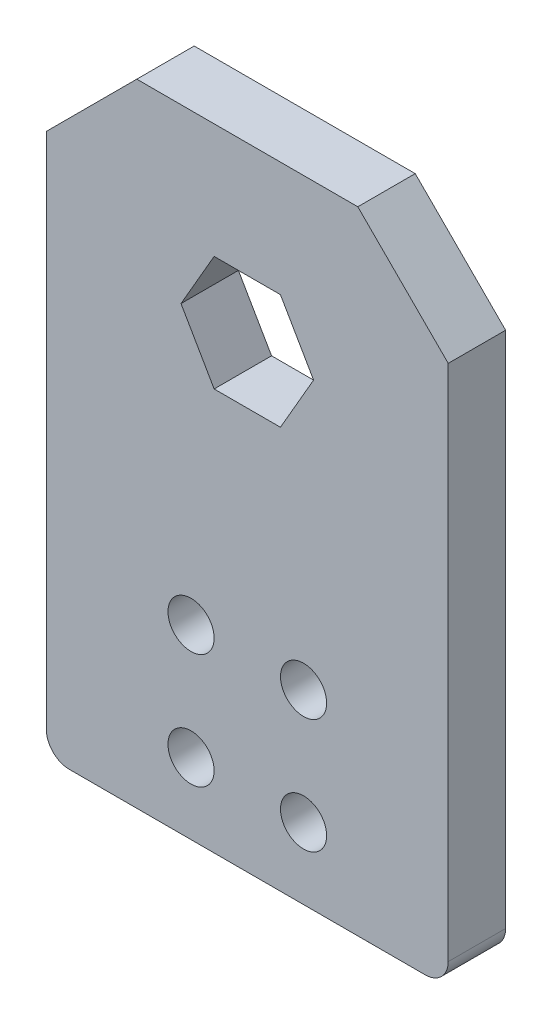
from build123d import *

# Parameters (mm, degrees)
SKETCH1_W                      = 44.45
SKETCH1_H                      = 69.85
BOSS_EXTRUDE1_DEPTH            = 3.175
CHAMFER1_SIZE                  = 10
CUT_EXTRUDE1_DEPTH             = 42.881126418
TAP_DRILL_FOR_10_24_TAP1_D     = 3.7973
TAP_DRILL_FOR_10_24_TAP1_DEPTH = 19.05
TAP_DRILL_FOR_10_24_TAP1_TIP   = 1.140824014
F_10_CLEARANCE_HOLE1_D         = 5.1054
F_10_CLEARANCE_HOLE1_DEPTH     = 12.7
F_10_CLEARANCE_HOLE1_TIP       = 1.533816902
FILLET1_R                      = 2.54


with BuildPart() as part:
    # Sketch1 → Boss-Extrude1 (new, symmetric)
    with BuildSketch(Plane.XY):
        Rectangle(SKETCH1_W, SKETCH1_H)
    extrude(amount=BOSS_EXTRUDE1_DEPTH, both=True)

    # Chamfer1
    chamfer1_edges = [part.edges().sort_by_distance(p)[0] for p in [
        (22.225, 34.925, 0),
        (-22.225, 34.925, 0),
    ]]
    chamfer(chamfer1_edges, length=CHAMFER1_SIZE)

    # Sketch2 → Cut-Extrude1 (cut, through all)
    with BuildSketch(Plane.XY.offset(3.175)):
        Polygon((7.332348419, 15.875), (3.666174209, 22.225), (-3.666174209, 22.225), (-7.332348419, 15.875), (-3.666174209, 9.525), (3.666174209, 9.525), align=None)
    extrude(amount=-CUT_EXTRUDE1_DEPTH, mode=Mode.SUBTRACT)

    # Tap Drill for _10-24 Tap1
    with Locations(Plane(origin=(0, -34.925, 0), x_dir=(-1, 0, 0), z_dir=(0, -1, 0))):
        with Locations((15.875, 0), (-15.875, 0)):
            Hole(TAP_DRILL_FOR_10_24_TAP1_D / 2, depth=TAP_DRILL_FOR_10_24_TAP1_DEPTH)
            with Locations((0, 0, -(TAP_DRILL_FOR_10_24_TAP1_DEPTH + TAP_DRILL_FOR_10_24_TAP1_TIP / 2))):  # 118° drill point
                Cone(0, TAP_DRILL_FOR_10_24_TAP1_D / 2, TAP_DRILL_FOR_10_24_TAP1_TIP, mode=Mode.SUBTRACT)

    # 10 Clearance Hole1
    with Locations(Plane.XY.offset(3.175)):
        with Locations((-6.223, -14.351), (6.223, -14.351), (6.223, -27.051), (-6.223, -27.051)):
            Hole(F_10_CLEARANCE_HOLE1_D / 2, depth=F_10_CLEARANCE_HOLE1_DEPTH)
            with Locations((0, 0, -(F_10_CLEARANCE_HOLE1_DEPTH + F_10_CLEARANCE_HOLE1_TIP / 2))):  # 118° drill point
                Cone(0, F_10_CLEARANCE_HOLE1_D / 2, F_10_CLEARANCE_HOLE1_TIP, mode=Mode.SUBTRACT)

    # Fillet1
    fillet1_edges = [part.edges().sort_by_distance(p)[0] for p in [
        (22.225, -34.925, 0),
        (-22.225, -34.925, 0),
    ]]
    fillet(fillet1_edges, radius=FILLET1_R)


solid = part.part
